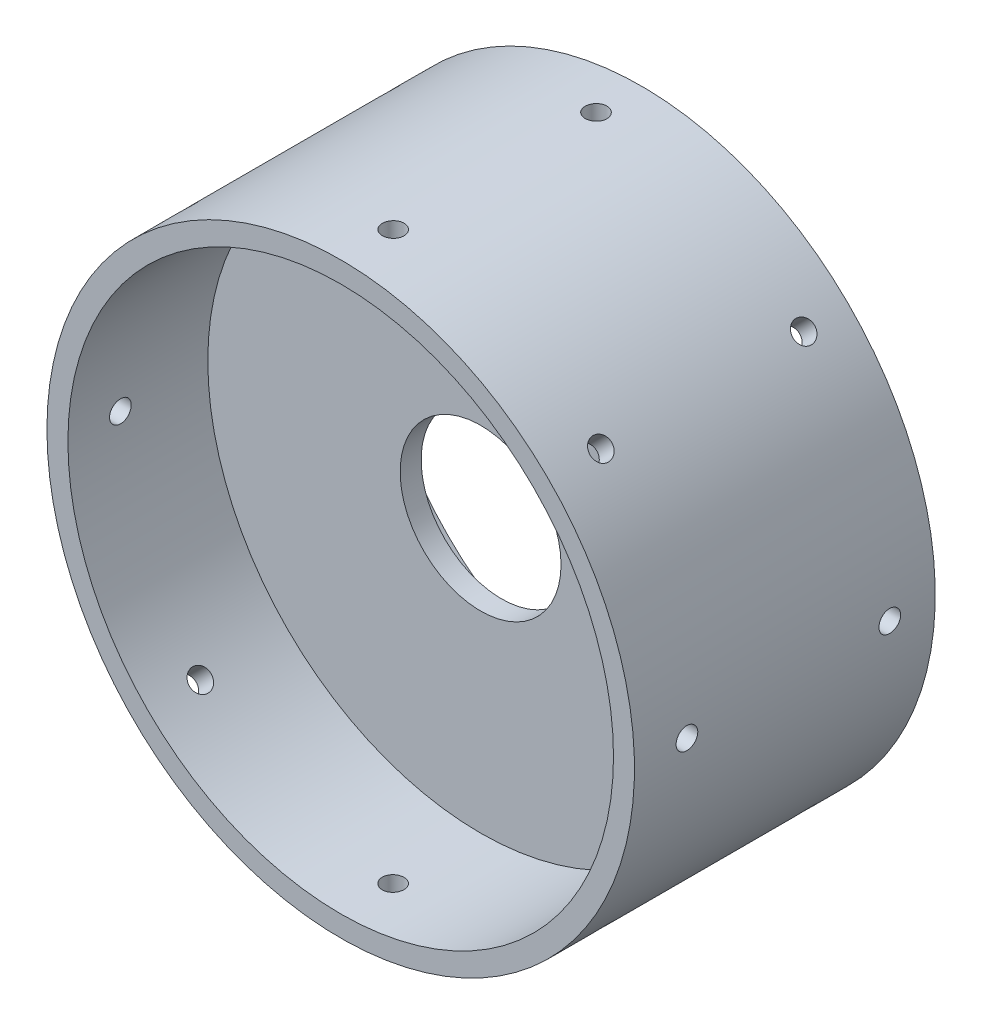
from build123d import *

# Parameters (mm, degrees)
ESQUISSE1_R                  = 42
BOSS_EXTRU_1_DEPTH           = 3
ESQUISSE5_W                  = 20
ESQUISSE5_H                  = 3
D_GAGEMENT_M2_51_D           = 3.1
R_P_TITION_CIRCULAIRE1_COUNT = 8
ESQUISSE8_R                  = 11.5
ENL_V_MAT_EXTRU_1_DEPTH      = 10


with BuildPart() as part:
    # Esquisse1 → Boss.-Extru.1 (new body)
    with BuildSketch(Plane.XY):
        Circle(ESQUISSE1_R)
    extrude(amount=BOSS_EXTRU_1_DEPTH)

    # Esquisse5 → Révolution1 (revolve)
    with BuildSketch(Plane(origin=(0, 0, 0), x_dir=(0, 0, -1), z_dir=(1, 0, 0)), mode=Mode.PRIVATE) as r_volution1_sk:
        with Locations((-13, 40.5)):
            Rectangle(ESQUISSE5_W, ESQUISSE5_H)
        with Locations((10, 40.5)):
            Rectangle(ESQUISSE5_W, ESQUISSE5_H)
    revolve(r_volution1_sk.sketch.rotate(Axis((0, 0, 0), (0, 0, 1)), 90), axis=Axis((0, 0, 0), (0, 0, 1)))

    # Dégagement M2.51 (through all)
    with Locations(Plane(origin=(42, 0, 15.5), x_dir=(0, 1, 0), z_dir=(1, 0, 0))):
        with Locations((0, 0), (0, -29)):
            d_gagement_m2_51 = Hole(D_GAGEMENT_M2_51_D / 2)

    # Répétition circulaire1: Dégagement M2.51 ×8 about axis
    r_p_tition_circulaire1_axis = Axis((0, 0, 0), (0, 0, -1))
    for i in range(1, R_P_TITION_CIRCULAIRE1_COUNT):
        add(d_gagement_m2_51.rotate(r_p_tition_circulaire1_axis, i * 360 / R_P_TITION_CIRCULAIRE1_COUNT), mode=Mode.SUBTRACT)

    # Esquisse8 → Enlèv. mat.-Extru.1 (cut)
    with BuildSketch(Plane.XY.offset(3)):
        Circle(ESQUISSE8_R)
    extrude(amount=-ENL_V_MAT_EXTRU_1_DEPTH, mode=Mode.SUBTRACT)


solid = part.part
